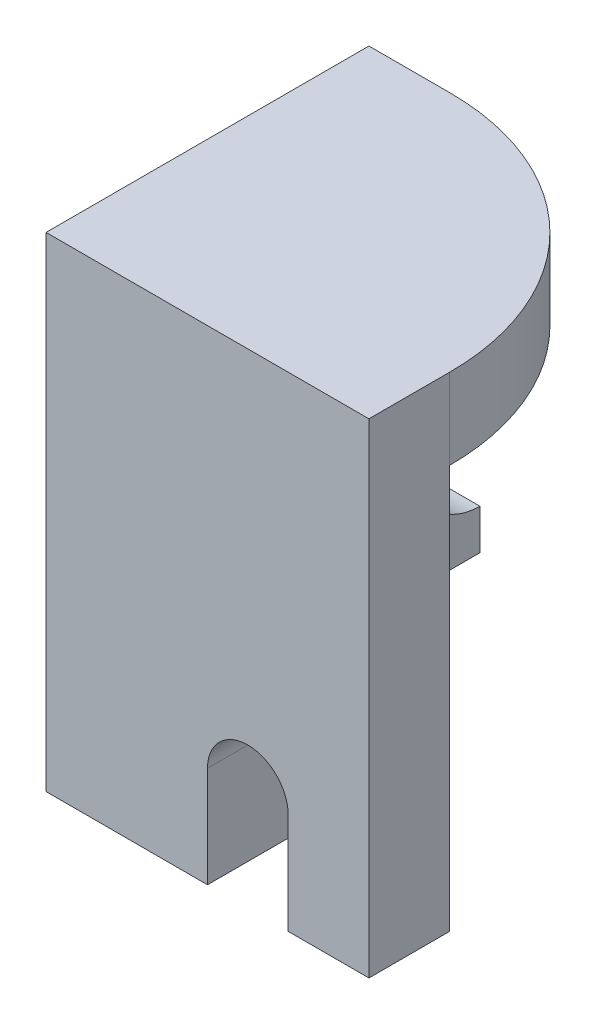
from build123d import *

# Parameters (mm, degrees)
BOSS_EXTRUDE1_DEPTH = 16
SKETCH3_W           = 64
SKETCH3_H           = 16
BOSS_EXTRUDE2_DEPTH = 80
CUT_EXTRUDE1_DEPTH  = 80
SKETCH5_W           = 42
SKETCH5_H           = 40
BOSS_EXTRUDE3_DEPTH = 28
SKETCH6_R           = 12
CUT_EXTRUDE2_DEPTH  = 51
BOSS_EXTRUDE4_DEPTH = 12


with BuildPart() as part:
    # Sketch1 → Boss-Extrude1 (new body)
    with BuildSketch(Plane(origin=(0, 0, 0), x_dir=(1, 0, 0), z_dir=(0, 1, 0))):
        with BuildLine():
            Line((-32, 32), (-16, 32))
            ThreePointArc((-16, 32), (17.941125497, 17.941125497), (32, -16))
            Line((32, -16), (32, -32))
            Line((32, -32), (-32, -32))
            Line((-32, -32), (-32, 32))
        make_face()
    extrude(amount=BOSS_EXTRUDE1_DEPTH)

    # Sketch3 → Boss-Extrude2 (add)
    with BuildSketch(Plane.XZ):
        with Locations((0, 24)):
            Rectangle(SKETCH3_W, SKETCH3_H)
    extrude(amount=BOSS_EXTRUDE2_DEPTH)

    # Sketch4 → Cut-Extrude1 (cut)
    with BuildSketch(Plane(origin=(0, 0, 16), x_dir=(-1, 0, 0), z_dir=(0, 0, -1))):
        with BuildLine():
            Line((-16, -80), (0, -80))
            Line((0, -80), (0, -60))
            ThreePointArc((0, -60), (-8, -52), (-16, -60))
            Line((-16, -60), (-16, -80))
        make_face()
    extrude(amount=-CUT_EXTRUDE1_DEPTH, mode=Mode.SUBTRACT)

    # Sketch5 → Boss-Extrude3 (add)
    with BuildSketch(Plane(origin=(0, 0, 16), x_dir=(-1, 0, 0), z_dir=(0, 0, -1))):
        with Locations((11, -20)):
            Rectangle(SKETCH5_W, SKETCH5_H)
    extrude(amount=BOSS_EXTRUDE3_DEPTH)

    # Sketch6 → Cut-Extrude2 (cut)
    with BuildSketch(Plane(origin=(10, 0, 0), x_dir=(0, 0, -1), z_dir=(1, 0, 0))):
        with Locations((12, -20)):
            Circle(SKETCH6_R)
    extrude(amount=-CUT_EXTRUDE2_DEPTH, mode=Mode.SUBTRACT)

    # Sketch7 → Boss-Extrude4 (add)
    with BuildSketch(Plane.ZY.offset(32)):
        Polygon((-12, -40), (16, -80), (16, -40), align=None)
    extrude(amount=-BOSS_EXTRUDE4_DEPTH)


solid = part.part
